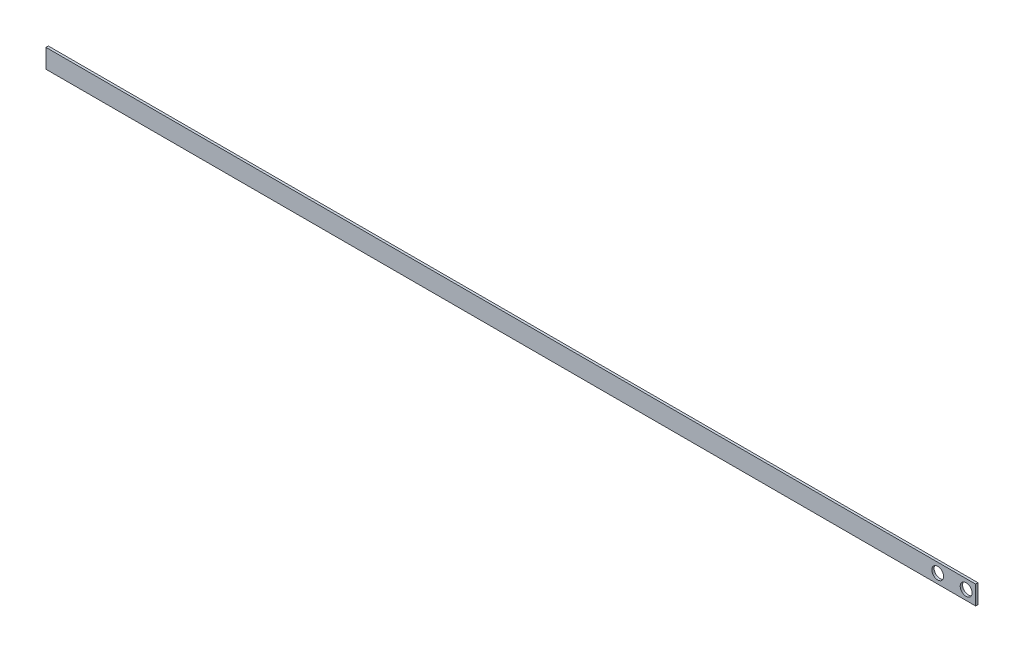
from build123d import *

# Parameters (mm, degrees)
SKETCH_1_W          = 196
SKETCH_1_H          = 4
EXTRUDE_1_DEPTH     = 0.5
SKETCH_2_R          = 1.25
CUT_EXTRUDE_1_DEPTH = 1


with BuildPart() as part:
    # ｽｹｯﾁ1 → ﾎﾞｽ - 押し出し1 (new body)
    with BuildSketch(Plane.XY):
        with Locations((98, -2)):
            Rectangle(SKETCH_1_W, SKETCH_1_H)
    extrude(amount=EXTRUDE_1_DEPTH)

    # ｽｹｯﾁ2 → ｶｯﾄ - 押し出し1 (cut)
    with BuildSketch(Plane.XY.offset(0.5)):
        with Locations((188, -2)):
            Circle(SKETCH_2_R)
        with Locations((194, -2)):
            Circle(SKETCH_2_R)
    extrude(amount=-CUT_EXTRUDE_1_DEPTH, mode=Mode.SUBTRACT)


solid = part.part
